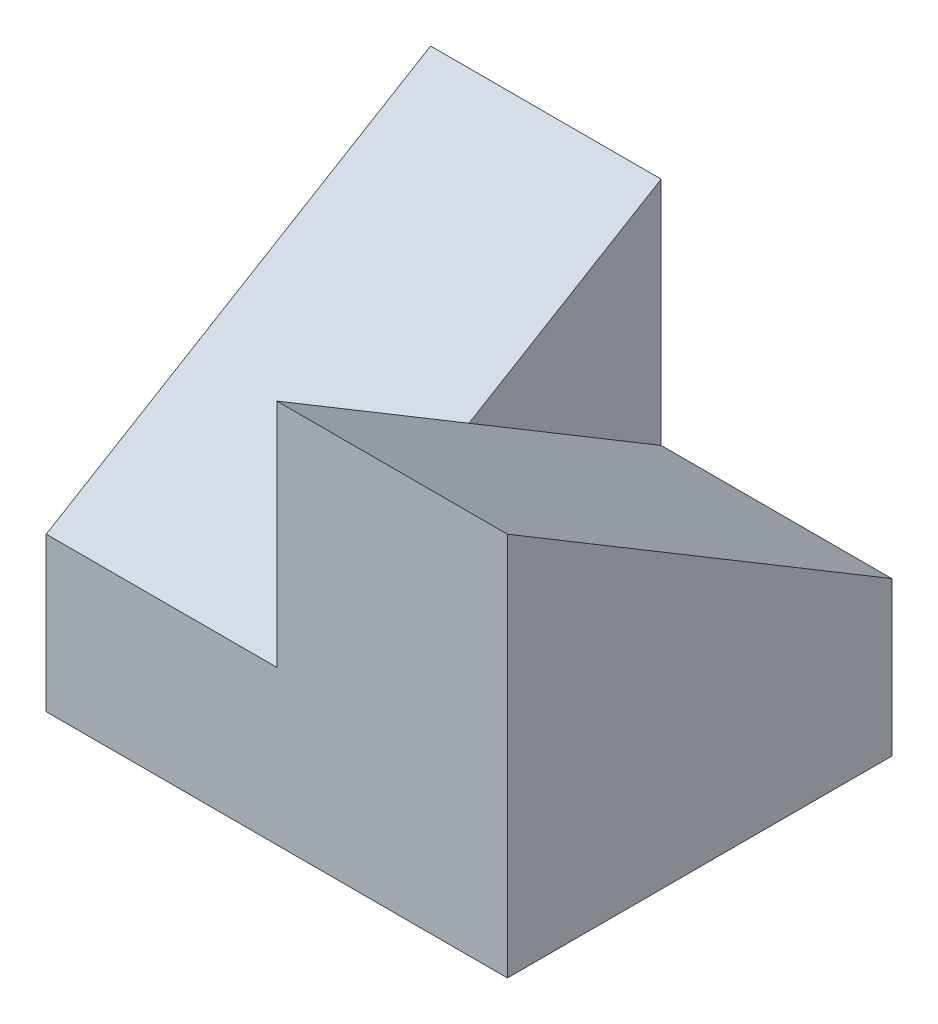
from build123d import *

# Parameters (mm, degrees)
BOSS_EXTRUDE1_DEPTH = 25
CUT_EXTRUDE1_DEPTH  = 25
BOSS_EXTRUDE2_DEPTH = 15


with BuildPart() as part:
    # Sketch1 → Boss-Extrude1 (new body)
    with BuildSketch(Plane.XY):
        Polygon((-30, 10), (-15, 10), (-15, 25), (0, 25), (0, 0), (-30, 0), align=None)
    extrude(amount=BOSS_EXTRUDE1_DEPTH)

    # Sketch2 → Cut-Extrude1 (cut)
    with BuildSketch(Plane.ZY.offset(15)):
        Polygon((0, 10), (25, 25), (0, 25), align=None)
    extrude(amount=-CUT_EXTRUDE1_DEPTH, mode=Mode.SUBTRACT)

    # Sketch4 → Boss-Extrude2 (add)
    with BuildSketch(Plane.ZY.offset(15)):
        Polygon((25, 10), (0, 10), (0, 25), align=None)
    extrude(amount=BOSS_EXTRUDE2_DEPTH)


solid = part.part
